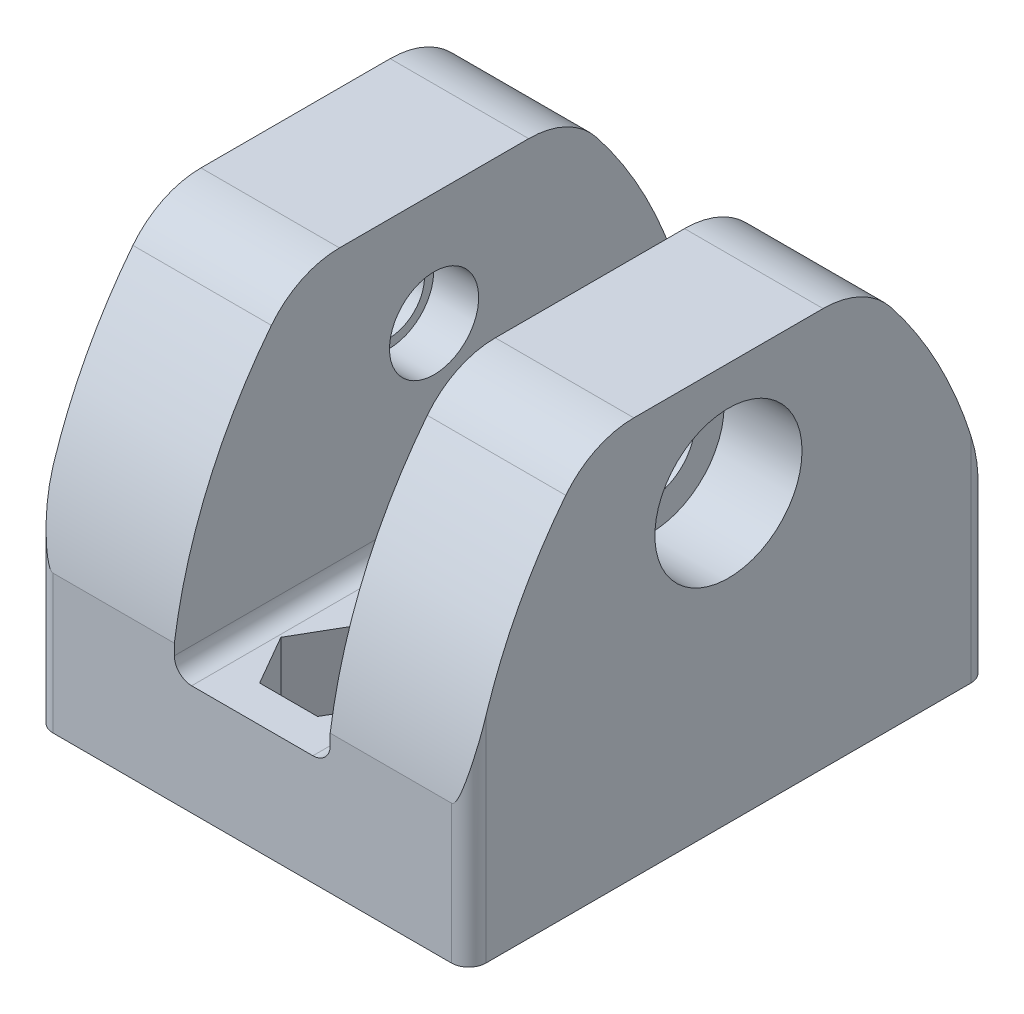
from build123d import *

# Parameters (mm, degrees)
CROQUIS1_W              = 25
CROQUIS1_H              = 30
CROQUIS1_R              = 1.55
SALIENTE_EXTRUIR1_DEPTH = 23
CROQUIS2_W              = 9
CROQUIS2_H              = 16.632666969
CORTAR_EXTRUIR1_DEPTH   = 30
CROQUIS3_R              = 2.575
CORTAR_EXTRUIR2_DEPTH   = 25
CORTAR_EXTRUIR3_DEPTH   = 2.5
CROQUIS5_R              = 4.25
CORTAR_EXTRUIR4_DEPTH   = 4.5
CORTAR_EXTRUIR5_DEPTH   = 4.5
CORTAR_EXTRUIR6_DEPTH   = 25
REDONDEO2_R             = 1
REDONDEO3_R             = 1
REDONDEO4_R             = 5
CROQUIS8_R              = 2.575
CROQUIS8_R_2            = 2.05
SALIENTE_EXTRUIR2_DEPTH = 2.9
CORTAR_EXTRUIR7_DEPTH   = 1.5


with BuildPart() as part:
    # Croquis1 → Saliente-Extruir1 (new body)
    with BuildSketch(Plane(origin=(0, 0, 0), x_dir=(1, 0, 0), z_dir=(0, 1, 0))):
        with Locations((12.5, 15)):
            Rectangle(CROQUIS1_W, CROQUIS1_H)
        with Locations((12.5, 25)):
            Circle(CROQUIS1_R, mode=Mode.SUBTRACT)
        with Locations((12.5, 5)):
            Circle(CROQUIS1_R, mode=Mode.SUBTRACT)
    extrude(amount=SALIENTE_EXTRUIR1_DEPTH)

    # Croquis2 → Cortar-Extruir1 (cut)
    with BuildSketch(Plane(origin=(0, 0, -30), x_dir=(-1, 0, 0), z_dir=(0, 0, -1))):
        with Locations((-12.5, 14.683666516)):
            Rectangle(CROQUIS2_W, CROQUIS2_H)
    extrude(amount=-CORTAR_EXTRUIR1_DEPTH, mode=Mode.SUBTRACT)

    # Croquis3 → Cortar-Extruir2 (cut)
    with BuildSketch(Plane.ZY):
        with Locations((-15, 16.5)):
            Circle(CROQUIS3_R)
    extrude(amount=-CORTAR_EXTRUIR2_DEPTH, mode=Mode.SUBTRACT)

    # Croquis4 → Cortar-Extruir3 (cut)
    with BuildSketch(Plane.ZY):
        Polygon((-14.95180736, 20.541164535), (-18.475654829, 18.562318318), (-18.523847469, 14.521153783), (-15.04819264, 12.458835465), (-11.524345171, 14.437681682), (-11.476152531, 18.478846217), align=None)
    extrude(amount=-CORTAR_EXTRUIR3_DEPTH, mode=Mode.SUBTRACT)

    # Croquis5 → Cortar-Extruir4 (cut)
    with BuildSketch(Plane(origin=(25, 0, 0), x_dir=(0, 0, -1), z_dir=(1, 0, 0))):
        with Locations((15, 16.5)):
            Circle(CROQUIS5_R)
    extrude(amount=-CORTAR_EXTRUIR4_DEPTH, mode=Mode.SUBTRACT)

    # Croquis6 → Cortar-Extruir5 (cut)
    with BuildSketch(Plane(origin=(0, 6.367333031, 0), x_dir=(1, 0, 0), z_dir=(0, 1, 0))):
        Polygon((15.848631561, 25), (14.174315781, 27.9), (10.825684219, 27.9), (9.151368439, 25), (10.825684219, 22.1), (14.174315781, 22.1), align=None)
        Polygon((15.848631561, 5), (14.174315781, 7.9), (10.825684219, 7.9), (9.151368439, 5), (10.825684219, 2.1), (14.174315781, 2.1), align=None)
    extrude(amount=-CORTAR_EXTRUIR5_DEPTH, mode=Mode.SUBTRACT)

    # Croquis7 → Cortar-Extruir6 (cut)
    with BuildSketch(Plane.ZY):
        with BuildLine():
            Line((-22.745966692, 23), (-30, 23))
            Line((-30, 23), (-30, 8))
            ThreePointArc((-30, 8), (-27.536048339, 16.062460813), (-22.745966692, 23))
        make_face()
        with BuildLine():
            Line((0, 23), (-7.254033308, 23))
            ThreePointArc((-7.254033308, 23), (-2.463951661, 16.062460813), (0, 8))
            Line((0, 8), (0, 23))
        make_face()
    extrude(amount=-CORTAR_EXTRUIR6_DEPTH, mode=Mode.SUBTRACT)

    # Redondeo2
    redondeo2_edges = [part.edges().sort_by_distance(p)[0] for p in [
        (8, 6.367333031, -15),
        (17, 6.367333031, -15),
    ]]
    fillet(redondeo2_edges, radius=REDONDEO2_R)

    # Redondeo3
    redondeo3_edges = [part.edges().sort_by_distance(p)[0] for p in [
        (25, 4, -30),
        (0, 4, -30),
        (25, 4, 0),
        (0, 4, 0),
    ]]
    fillet(redondeo3_edges, radius=REDONDEO3_R)

    # Redondeo4
    redondeo4_edges = [part.edges().sort_by_distance(p)[0] for p in [
        (4, 23, -22.745966692),
        (21, 23, -22.745966692),
        (4, 23, -7.254033308),
        (21, 23, -7.254033308),
    ]]
    fillet(redondeo4_edges, radius=REDONDEO4_R)

    # Croquis8 → Saliente-Extruir2 (add)
    with BuildSketch(Plane.ZY.offset(-2.5)):
        with Locations((-15, 16.5)):
            Circle(CROQUIS8_R)
        with Locations((-15, 16.5)):
            Circle(CROQUIS8_R_2, mode=Mode.SUBTRACT)
    extrude(amount=-SALIENTE_EXTRUIR2_DEPTH)

    # Croquis9 → Cortar-Extruir7 (cut)
    with BuildSketch(Plane.ZY.offset(-2.5)):
        Polygon((-11.476152531, 18.478846217), (-14.95180736, 20.541164535), (-18.475654829, 18.562318318), (-18.523847469, 14.521153783), (-15.04819264, 12.458835465), (-11.524345171, 14.437681682), align=None)
    extrude(amount=-CORTAR_EXTRUIR7_DEPTH, mode=Mode.SUBTRACT)


solid = part.part
